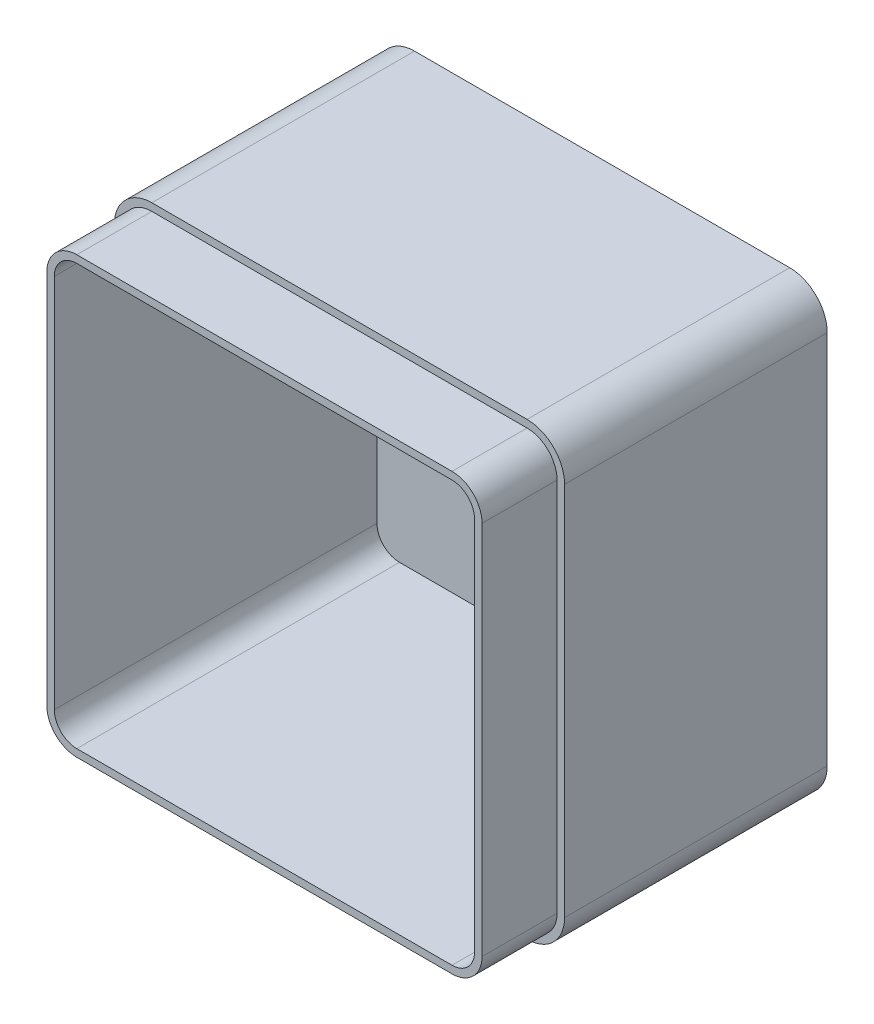
from build123d import *

# Parameters (mm, degrees)
SKETCH1_W           = 120
SKETCH1_H           = 120
BOSS_EXTRUDE1_DEPTH = 90
FILLET1_R           = 10
SHELL1_T            = -4
CUT_EXTRUDE1_DEPTH  = 20


with BuildPart() as part:
    # Sketch1 → Boss-Extrude1 (new body)
    with BuildSketch(Plane.XY):
        Rectangle(SKETCH1_W, SKETCH1_H)
    extrude(amount=BOSS_EXTRUDE1_DEPTH)

    # Fillet1
    fillet1_edges = [part.edges().sort_by_distance(p)[0] for p in [
        (60, -60, 45),
        (-60, -60, 45),
        (-60, 60, 45),
        (60, 60, 45),
    ]]
    fillet(fillet1_edges, radius=FILLET1_R)

    # Shell1
    shell1_openings = [part.faces().sort_by_distance(p)[0] for p in [
        (0, 0, 90),
    ]]
    offset(amount=SHELL1_T, openings=shell1_openings, kind=Kind.INTERSECTION)

    # Sketch2 → Cut-Extrude1 (cut)
    with BuildSketch(Plane.XY.offset(90)):
        with BuildLine():
            Line((-60, 50), (-60, -50))
            ThreePointArc((-60, -50), (-57.071067812, -57.071067812), (-50, -60))
            Line((-50, -60), (50, -60))
            ThreePointArc((50, -60), (57.071067812, -57.071067812), (60, -50))
            Line((60, -50), (60, 50))
            ThreePointArc((60, 50), (57.071067812, 57.071067812), (50, 60))
            Line((50, 60), (-50, 60))
            ThreePointArc((-50, 60), (-57.071067812, 57.071067812), (-60, 50))
        make_face()
        with BuildLine():
            Line((-58, 50), (-58, -50))
            ThreePointArc((-58, -50), (-55.656854249, -55.656854249), (-50, -58))
            Line((-50, -58), (50, -58))
            ThreePointArc((50, -58), (55.656854249, -55.656854249), (58, -50))
            Line((58, -50), (58, 50))
            ThreePointArc((58, 50), (55.656854249, 55.656854249), (50, 58))
            Line((50, 58), (-50, 58))
            ThreePointArc((-50, 58), (-55.656854249, 55.656854249), (-58, 50))
        make_face(mode=Mode.SUBTRACT)
    extrude(amount=-CUT_EXTRUDE1_DEPTH, mode=Mode.SUBTRACT)


solid = part.part
